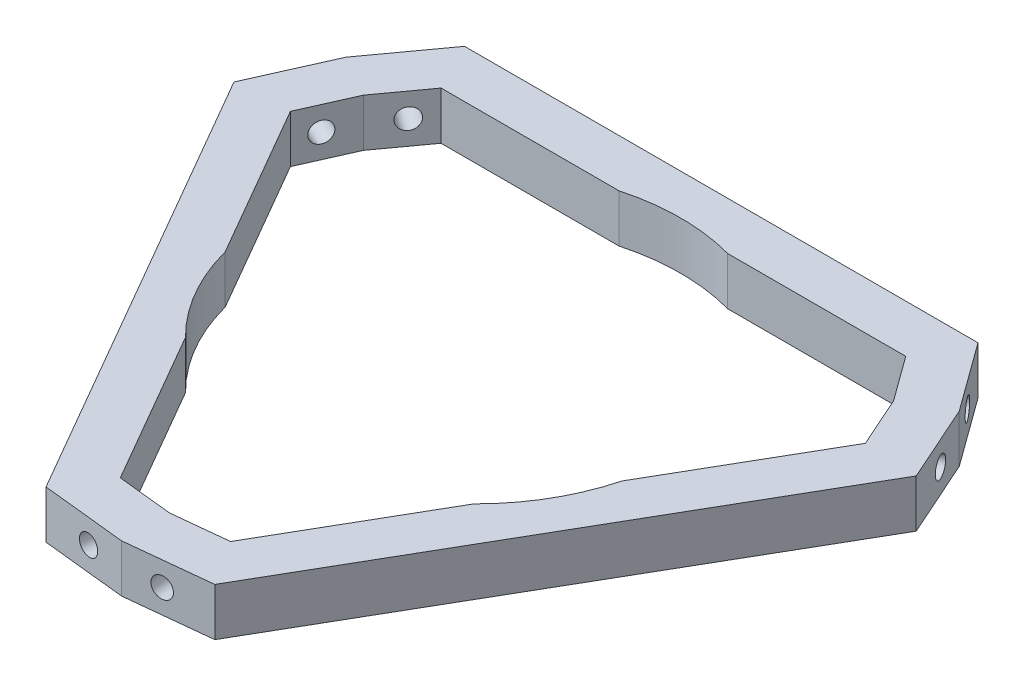
from build123d import *

# Parameters (mm, degrees)
EXTRUDE_1_DEPTH          = 3.5
PATTERN_CIRCULAR_1_COUNT = 3


with BuildPart() as part:
    # Эскиз1 → Бобышка-Вытянуть1 (new, symmetric)
    with BuildSketch(Plane(origin=(0, 0, 0), x_dir=(1, 0, 0), z_dir=(0, 1, 0))):
        Polygon((-44.845979262, 25.891838199), (-49.89474757, 14.552118915), (-12.344869126, -50.486178369), (0, -51.783676398), (12.344869126, -50.486178369), (49.89474757, 14.552118915), (44.845979262, 25.891838199), (37.549878444, 35.934059454), (-37.549878444, 35.934059454), align=None)
        with BuildLine():
            Line((-38.750409265, 22.37255922), (-33.983200298, 28.934059454))
            Line((-33.983200298, 28.934059454), (-7.925919728, 28.934059454))
            ThreePointArc((-7.925919728, 28.934059454), (0, 30), (7.925919728, 28.934059454))
            Line((7.925919728, 28.934059454), (33.983200298, 28.934059454))
            Line((33.983200298, 28.934059454), (38.750409265, 22.37255922))
            Line((38.750409265, 22.37255922), (42.04923067, 14.963285033))
            Line((42.04923067, 14.963285033), (29.020590385, -7.602981894))
            ThreePointArc((29.020590385, -7.602981894), (25.980762114, -15), (21.094670658, -21.331077559))
            Line((21.094670658, -21.331077559), (8.066030373, -43.897344487))
            Line((8.066030373, -43.897344487), (0, -44.745118441))
            Line((0, -44.745118441), (-8.066030373, -43.897344487))
            Line((-8.066030373, -43.897344487), (-21.094670658, -21.331077559))
            ThreePointArc((-21.094670658, -21.331077559), (-25.980762114, -15), (-29.020590385, -7.602981894))
            Line((-29.020590385, -7.602981894), (-42.04923067, 14.963285033))
            Line((-42.04923067, 14.963285033), (-38.750409265, 22.37255922))
        make_face(mode=Mode.SUBTRACT)
    extrude(amount=EXTRUDE_1_DEPTH, both=True)

    # Эскиз1<3> → Вырез-Повернуть1 (revolve, cut)
    with BuildSketch(Plane(origin=(0, 0, 0), x_dir=(1, 0, 0), z_dir=(0, 1, 0))):
        Polygon((-41.26287783, 16.72946243), (-40.652772865, 18.099780617), (-47.047591069, 20.946937118), (-47.657696033, 19.576618932), align=None)
    cut_revolve_1 = revolve(axis=Axis((0, 0, 0), (-0.9135454576426014, 0, -0.406736643075799)), mode=Mode.SUBTRACT)

    # Эскиз1<4> → Вырез-Повернуть2 (revolve, cut)
    with BuildSketch(Plane(origin=(0, 0, 0), x_dir=(1, 0, 0), z_dir=(0, 1, 0))):
        Polygon((-41.66437521, 30.270940493), (-36.00125625, 26.156443727), (-35.119578371, 27.369969219), (-40.782697332, 31.484465985), align=None)
    cut_revolve_2 = revolve(axis=Axis((0, 0, 0), (-0.8090169943749476, 0, -0.587785252292473)), mode=Mode.SUBTRACT)

    # Круговой массив1: Вырез-Повернуть1, Вырез-Повернуть2 ×3 about axis
    pattern_circular_1_axis = Axis((0, 3.5, 0), (0, -1, 0))
    add([cut_revolve_1.rotate(pattern_circular_1_axis, i * 360 / PATTERN_CIRCULAR_1_COUNT) for i in range(1, PATTERN_CIRCULAR_1_COUNT)], mode=Mode.SUBTRACT)
    add([cut_revolve_2.rotate(pattern_circular_1_axis, i * 360 / PATTERN_CIRCULAR_1_COUNT) for i in range(1, PATTERN_CIRCULAR_1_COUNT)], mode=Mode.SUBTRACT)


solid = part.part
